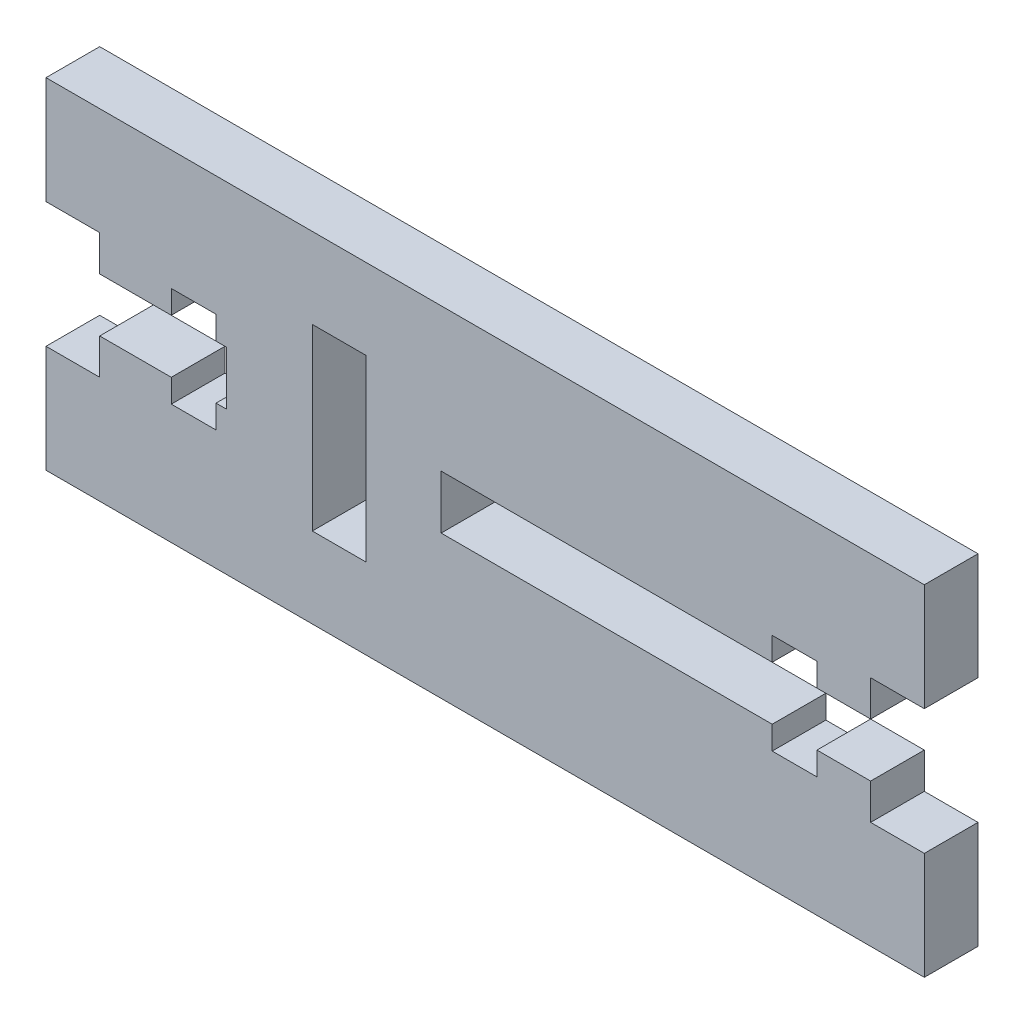
from build123d import *

# Parameters (mm, degrees)
MODEL_W             = 3
MODEL_H             = 9.9999
BOSS_EXTRUDE1_DEPTH = 3


with BuildPart() as part:
    # Model → Boss-Extrude1 (new body)
    with BuildSketch(Plane.XY):
        Polygon((73.79, 50.5), (24.71, 50.5), (24.71, 44.5), (27.71, 44.5), (27.71, 42.5), (31.71, 42.5), (31.71, 43.8), (34.21, 43.8), (34.21, 42.5), (34.81, 42.5), (34.81, 39.5), (34.21, 39.5), (34.21, 38.2), (31.71, 38.2), (31.71, 39.5), (27.71, 39.5), (27.71, 37.5), (24.71, 37.5), (24.71, 31.5), (46.51, 31.5), (73.79, 31.5), (73.79, 37.5), (70.79, 37.5), (70.79, 39.5), (67.79, 39.5), (67.79, 38.2), (65.29, 38.2), (65.29, 39.5), (46.79, 39.5), (46.79, 42.5), (65.29, 42.5), (65.29, 43.8), (67.79, 43.8), (67.79, 42.5), (70.79, 42.5), (70.79, 44.5), (73.79, 44.5), align=None)
        with Locations((41.09, 41.00005)):
            Rectangle(MODEL_W, MODEL_H, mode=Mode.SUBTRACT)
    extrude(amount=BOSS_EXTRUDE1_DEPTH)


solid = part.part
